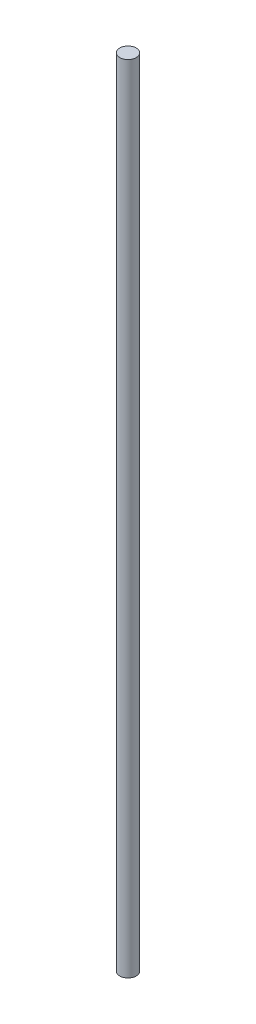
from build123d import *

# Parameters (mm, degrees)
SKETCH1_R           = 2.38125
BOSS_EXTRUDE1_DEPTH = 228.6


with BuildPart() as part:
    # Sketch1 → Boss-Extrude1 (new body)
    with BuildSketch(Plane(origin=(0, 0, 0), x_dir=(1, 0, 0), z_dir=(0, 1, 0))):
        Circle(SKETCH1_R)
    extrude(amount=BOSS_EXTRUDE1_DEPTH)


solid = part.part
